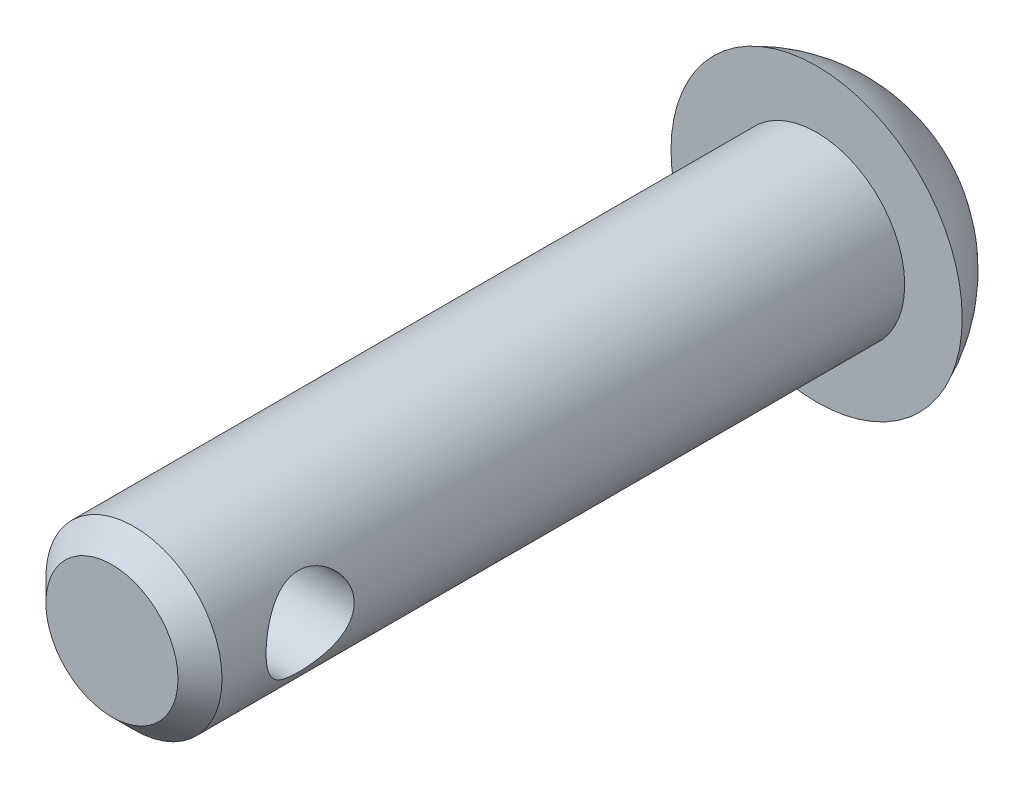
from build123d import *

# Parameters (mm, degrees)
SKETCH1_R               = 2
BOSS_EXTRUDE1_DEPTH     = 16
CHAMFER1_SIZE           = 0.5
SKETCH7_R               = 1
CUT_EXTRUDE1_DEPTH      = 4.305898307
CUT_EXTRUDE1_DEPTH_BACK = 4.305898307


with BuildPart() as part:
    # Sketch1 → Boss-Extrude1 (new body)
    with BuildSketch(Plane.XY):
        Circle(SKETCH1_R)
    extrude(amount=-BOSS_EXTRUDE1_DEPTH)

    # Chamfer1
    chamfer1_edges = [part.edges().sort_by_distance(p)[0] for p in [
        (-2, 0, 0),
    ]]
    chamfer(chamfer1_edges, length=CHAMFER1_SIZE)

    # Sketch4 → Revolve1 (revolve)
    with BuildSketch(Plane(origin=(0, 0, 0), x_dir=(0, 0, -1), z_dir=(1, 0, 0))):
        with BuildLine():
            Line((16, 0), (16, 3.305898307))
            ThreePointArc((16, 3.305898307), (17.582389504, 1.978570239), (18.174855662, 0))
            Line((18.174855662, 0), (16, 0))
        make_face()
    revolve(axis=Axis((0, 0, -13.297823311), (0, 0, -1)))

    # Sketch7 → Cut-Extrude1 (cut, two sides)
    with BuildSketch(Plane(origin=(0, 0, 0), x_dir=(0, 0, -1), z_dir=(1, 0, 0))) as cut_extrude1_sk:
        with Locations((2.5, 0)):
            Circle(SKETCH7_R)
    extrude(amount=CUT_EXTRUDE1_DEPTH, mode=Mode.SUBTRACT)
    extrude(cut_extrude1_sk.sketch, amount=-CUT_EXTRUDE1_DEPTH_BACK, mode=Mode.SUBTRACT)


solid = part.part
